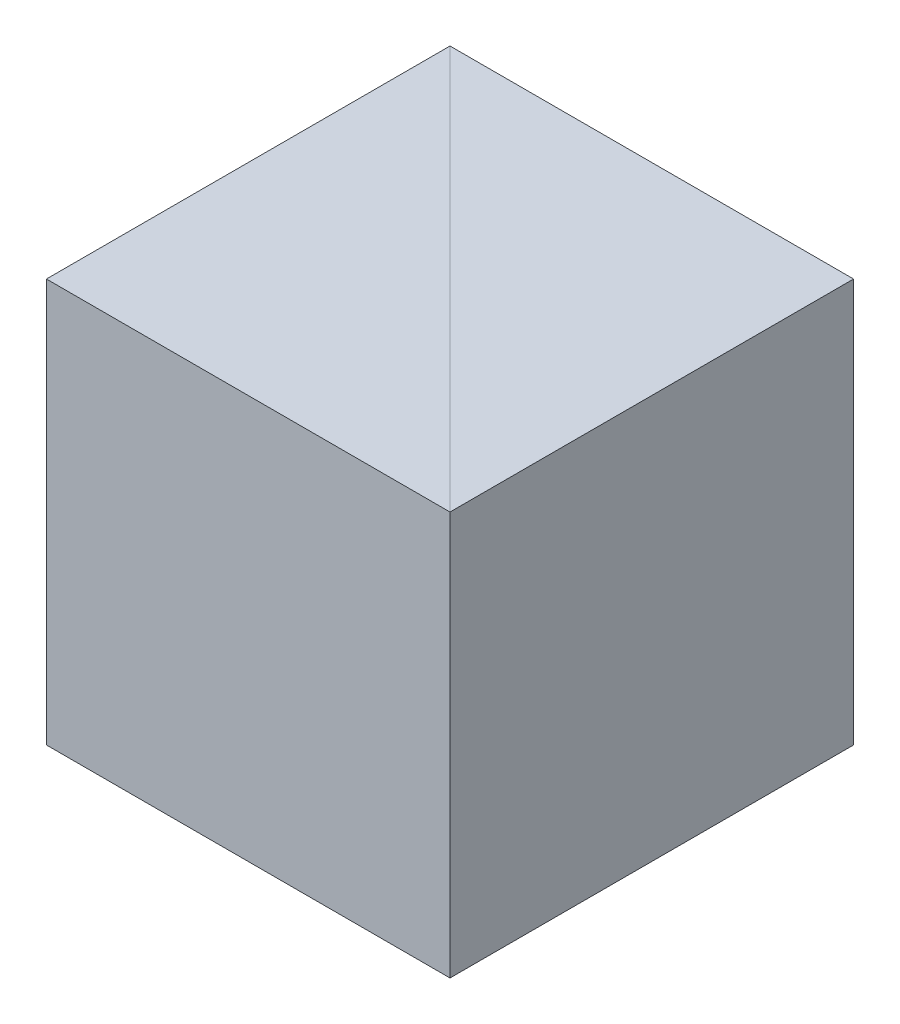
from build123d import *

# Parameters (mm, degrees)
EXTRUDE_1_DEPTH = 12.7
EXTRUDE_2_DEPTH = 12.7


with BuildPart() as part:
    # 草图1 → 凸台-拉伸1 (new body)
    with BuildSketch(Plane(origin=(0, 0, 0), x_dir=(1, 0, 0), z_dir=(0, 1, 0))):
        Polygon((0, 0), (0, 12.7), (-12.7, 12.7), align=None)
    extrude(amount=EXTRUDE_1_DEPTH)


with BuildPart() as body_2:
    # 草图2 → 凸台-拉伸2 (new body)
    with BuildSketch(Plane.XZ):
        Polygon((-12.7, -12.7), (-12.7, 0), (0, 0), align=None)
    extrude(amount=-EXTRUDE_2_DEPTH)


solid = Compound([part.part, body_2.part])
